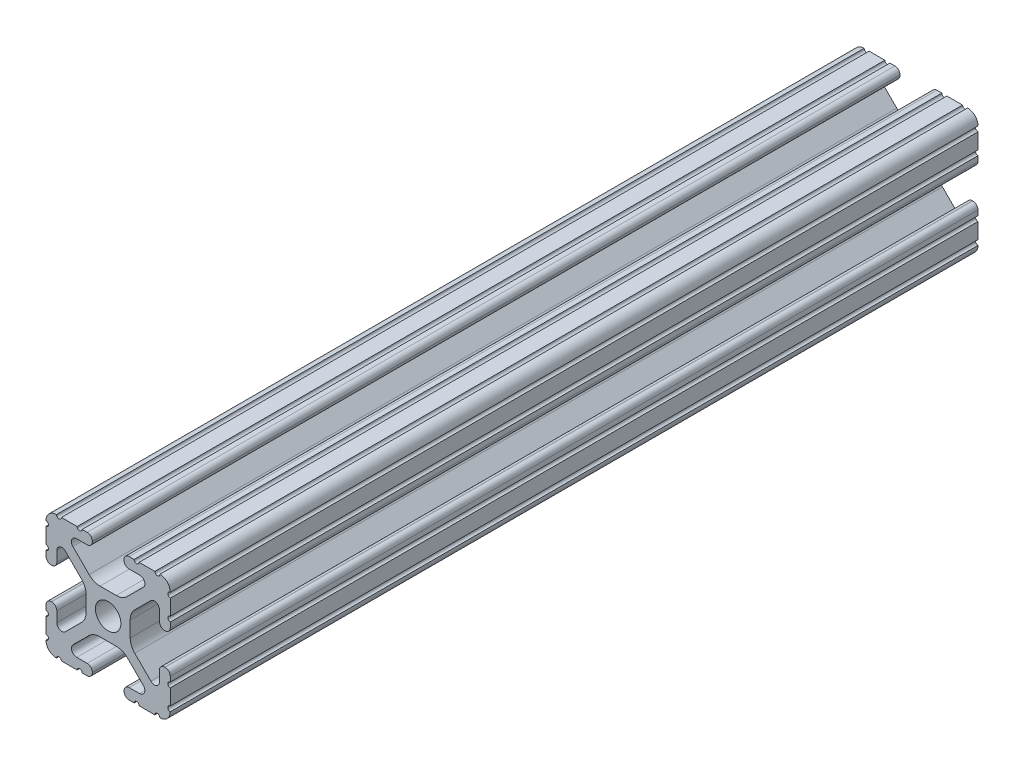
from build123d import *

# Parameters (mm, degrees)
SKETCH1_R           = 2.6035
BOSS_EXTRUDE1_DEPTH = 82.55


with BuildPart() as part:
    # Sketch1 → Boss-Extrude1 (new body, symmetric)
    with BuildSketch(Plane.XY):
        with BuildLine():
            Line((-7.179650497, -8.645192506), (-3.952270251, -5.423690499))
            ThreePointArc((-3.952270251, -5.423690499), (-2.922936451, -4.736929036), (-1.709253557, -4.4958))
            Line((-1.709253557, -4.4958), (1.709253557, -4.4958))
            ThreePointArc((1.709253557, -4.4958), (2.922936451, -4.736929036), (3.952270251, -5.423690499))
            Line((3.952270251, -5.423690499), (7.179650497, -8.645192506))
            ThreePointArc((7.179650497, -8.645192506), (7.41473083, -9.822813117), (6.416408329, -10.4902))
            Line((6.416408329, -10.4902), (4.287512407, -10.4902))
            ThreePointArc((4.287512407, -10.4902), (3.54574862, -10.79744862), (3.2385, -11.539212407))
            Line((3.2385, -11.539212407), (3.2385, -11.650987593))
            ThreePointArc((3.2385, -11.650987593), (3.54574862, -12.39275138), (4.287512407, -12.7))
            Line((4.287512407, -12.7), (5.317126718, -12.7))
            ThreePointArc((5.317126718, -12.7), (5.825126718, -12.192), (6.333126718, -12.7))
            Line((6.333126718, -12.7), (9.550443118, -12.7))
            ThreePointArc((9.550443118, -12.7), (10.058366869, -12.192000006), (10.566443095, -12.699847501))
            ThreePointArc((10.566443095, -12.699847501), (12.082537762, -12.08250727), (12.699846982, -10.566399977))
            ThreePointArc((12.699846982, -10.566399977), (12.192000006, -10.058323491), (12.7, -9.5504))
            Line((12.7, -9.5504), (12.7, -6.3330836))
            ThreePointArc((12.7, -6.3330836), (12.192, -5.8250836), (12.7, -5.3170836))
            Line((12.7, -5.3170836), (12.7, -4.287469289))
            ThreePointArc((12.7, -4.287469289), (12.39275138, -3.545705502), (11.650987593, -3.238456882))
            Line((11.650987593, -3.238456882), (11.539212407, -3.238456882))
            ThreePointArc((11.539212407, -3.238456882), (10.79744862, -3.545705502), (10.4902, -4.287469289))
            Line((10.4902, -4.287469289), (10.4902, -6.402089023))
            ThreePointArc((10.4902, -6.402089023), (9.856505071, -7.351067942), (8.737131347, -7.129408934))
            Line((8.737131347, -7.129408934), (5.441005833, -3.840816462))
            ThreePointArc((5.441005833, -3.840816462), (4.750877967, -2.809883091), (4.5085, -1.593185507))
            Line((4.5085, -1.593185507), (4.5085, 1.593185507))
            ThreePointArc((4.5085, 1.593185507), (4.750877967, 2.809883091), (5.441005833, 3.840816462))
            Line((5.441005833, 3.840816462), (8.737131347, 7.129408934))
            ThreePointArc((8.737131347, 7.129408934), (9.856505071, 7.351067942), (10.4902, 6.402089023))
            Line((10.4902, 6.402089023), (10.4902, 4.287469289))
            ThreePointArc((10.4902, 4.287469289), (10.79744862, 3.545705502), (11.539212407, 3.238456882))
            Line((11.539212407, 3.238456882), (11.650987593, 3.238456882))
            ThreePointArc((11.650987593, 3.238456882), (12.39275138, 3.545705502), (12.7, 4.287469289))
            Line((12.7, 4.287469289), (12.7, 5.3170836))
            ThreePointArc((12.7, 5.3170836), (12.192, 5.8250836), (12.7, 6.3330836))
            Line((12.7, 6.3330836), (12.7, 9.5504))
            ThreePointArc((12.7, 9.5504), (12.192000006, 10.058323491), (12.699846982, 10.566399977))
            ThreePointArc((12.699846982, 10.566399977), (12.082537762, 12.08250727), (10.566443095, 12.699847501))
            ThreePointArc((10.566443095, 12.699847501), (10.058366869, 12.192000006), (9.550443118, 12.7))
            Line((9.550443118, 12.7), (6.333126718, 12.7))
            ThreePointArc((6.333126718, 12.7), (5.825126718, 12.192), (5.317126718, 12.7))
            Line((5.317126718, 12.7), (4.287512407, 12.7))
            ThreePointArc((4.287512407, 12.7), (3.54574862, 12.39275138), (3.2385, 11.650987593))
            Line((3.2385, 11.650987593), (3.2385, 11.539212407))
            ThreePointArc((3.2385, 11.539212407), (3.54574862, 10.79744862), (4.287512407, 10.4902))
            Line((4.287512407, 10.4902), (6.476788598, 10.4902))
            ThreePointArc((6.476788598, 10.4902), (7.432222385, 9.85140422), (7.207036008, 8.724370562))
            Line((7.207036008, 8.724370562), (3.898272566, 5.423169045))
            ThreePointArc((3.898272566, 5.423169045), (2.869120213, 4.736787962), (1.655778399, 4.4958))
            Line((1.655778399, 4.4958), (-1.655778399, 4.4958))
            ThreePointArc((-1.655778399, 4.4958), (-2.869120213, 4.736787962), (-3.898272566, 5.423169045))
            Line((-3.898272566, 5.423169045), (-7.207036008, 8.724370562))
            ThreePointArc((-7.207036008, 8.724370562), (-7.432222385, 9.85140422), (-6.476788598, 10.4902))
            Line((-6.476788598, 10.4902), (-4.287512407, 10.4902))
            ThreePointArc((-4.287512407, 10.4902), (-3.54574862, 10.79744862), (-3.2385, 11.539212407))
            Line((-3.2385, 11.539212407), (-3.2385, 11.650987593))
            ThreePointArc((-3.2385, 11.650987593), (-3.54574862, 12.39275138), (-4.287512407, 12.7))
            Line((-4.287512407, 12.7), (-5.317126718, 12.7))
            ThreePointArc((-5.317126718, 12.7), (-5.825126718, 12.192), (-6.333126718, 12.7))
            Line((-6.333126718, 12.7), (-9.550443118, 12.7))
            ThreePointArc((-9.550443118, 12.7), (-10.058366869, 12.192000006), (-10.566443095, 12.699847501))
            ThreePointArc((-10.566443095, 12.699847501), (-12.082537762, 12.08250727), (-12.699846982, 10.566399977))
            ThreePointArc((-12.699846982, 10.566399977), (-12.192000006, 10.058323491), (-12.7, 9.5504))
            Line((-12.7, 9.5504), (-12.7, 6.3330836))
            ThreePointArc((-12.7, 6.3330836), (-12.192, 5.8250836), (-12.7, 5.3170836))
            Line((-12.7, 5.3170836), (-12.7, 4.287469289))
            ThreePointArc((-12.7, 4.287469289), (-12.39275138, 3.545705502), (-11.650987593, 3.238456882))
            Line((-11.650987593, 3.238456882), (-11.539212407, 3.238456882))
            ThreePointArc((-11.539212407, 3.238456882), (-10.79744862, 3.545705502), (-10.4902, 4.287469289))
            Line((-10.4902, 4.287469289), (-10.4902, 6.402089023))
            ThreePointArc((-10.4902, 6.402089023), (-9.856505071, 7.351067942), (-8.737131347, 7.129408934))
            Line((-8.737131347, 7.129408934), (-5.441005833, 3.840816462))
            ThreePointArc((-5.441005833, 3.840816462), (-4.750877967, 2.809883091), (-4.5085, 1.593185507))
            Line((-4.5085, 1.593185507), (-4.5085, -1.593185507))
            ThreePointArc((-4.5085, -1.593185507), (-4.750877967, -2.809883091), (-5.441005833, -3.840816462))
            Line((-5.441005833, -3.840816462), (-8.737131347, -7.129408934))
            ThreePointArc((-8.737131347, -7.129408934), (-9.856505071, -7.351067942), (-10.4902, -6.402089023))
            Line((-10.4902, -6.402089023), (-10.4902, -4.287469289))
            ThreePointArc((-10.4902, -4.287469289), (-10.79744862, -3.545705502), (-11.539212407, -3.238456882))
            Line((-11.539212407, -3.238456882), (-11.650987593, -3.238456882))
            ThreePointArc((-11.650987593, -3.238456882), (-12.39275138, -3.545705502), (-12.7, -4.287469289))
            Line((-12.7, -4.287469289), (-12.7, -5.3170836))
            ThreePointArc((-12.7, -5.3170836), (-12.192, -5.8250836), (-12.7, -6.3330836))
            Line((-12.7, -6.3330836), (-12.7, -9.5504))
            ThreePointArc((-12.7, -9.5504), (-12.192000006, -10.058323491), (-12.699846982, -10.566399977))
            ThreePointArc((-12.699846982, -10.566399977), (-12.082537762, -12.08250727), (-10.566443095, -12.699847501))
            ThreePointArc((-10.566443095, -12.699847501), (-10.058366869, -12.192000006), (-9.550443118, -12.7))
            Line((-9.550443118, -12.7), (-6.333126718, -12.7))
            ThreePointArc((-6.333126718, -12.7), (-5.825126718, -12.192), (-5.317126718, -12.7))
            Line((-5.317126718, -12.7), (-4.287512407, -12.7))
            ThreePointArc((-4.287512407, -12.7), (-3.54574862, -12.39275138), (-3.2385, -11.650987593))
            Line((-3.2385, -11.650987593), (-3.2385, -11.539212407))
            ThreePointArc((-3.2385, -11.539212407), (-3.54574862, -10.79744862), (-4.287512407, -10.4902))
            Line((-4.287512407, -10.4902), (-6.416408329, -10.4902))
            ThreePointArc((-6.416408329, -10.4902), (-7.41473083, -9.822813117), (-7.179650497, -8.645192506))
        make_face()
        Circle(SKETCH1_R, mode=Mode.SUBTRACT)
    extrude(amount=BOSS_EXTRUDE1_DEPTH, both=True)


solid = part.part
